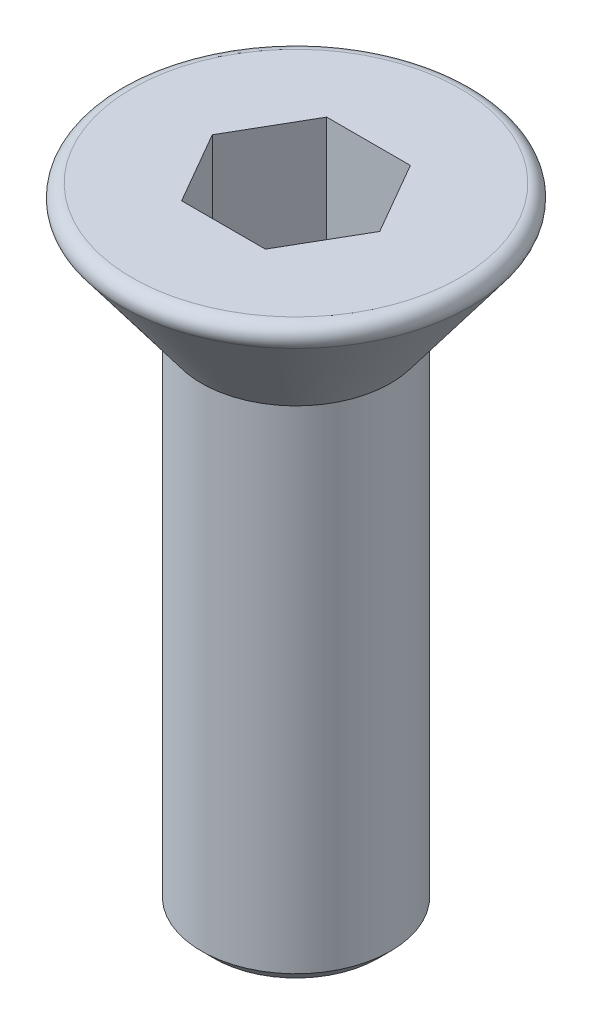
from build123d import *

# Parameters (mm, degrees)
SKETCH_2_R          = 1.5
EXTRUDE_1_DEPTH     = 8
CUT_EXTRUDE_1_DEPTH = 2
CHAMFER_1_SIZE      = 0.2
FILLET_1_R          = 0.2


with BuildPart() as part:
    # 草图1 → 旋转1 (revolve)
    with BuildSketch(Plane.XY):
        Polygon((0, 0), (0, -2), (1.5, -2), (3, 0), align=None)
    revolve(axis=Axis((0, 0, 0), (0, -1, 0)))

    # 草图2 → 凸台-拉伸1 (add)
    with BuildSketch(Plane.XZ.offset(2)):
        Circle(SKETCH_2_R)
    extrude(amount=EXTRUDE_1_DEPTH)

    # 草图3 → 切除-拉伸1 (cut)
    with BuildSketch(Plane(origin=(0, 0, 0), x_dir=(1, 0, 0), z_dir=(0, 1, 0))):
        Polygon((-1.327905619, 0), (-0.66395281, -1.15), (0.66395281, -1.15), (1.327905619, 0), (0.66395281, 1.15), (-0.66395281, 1.15), align=None)
    extrude(amount=-CUT_EXTRUDE_1_DEPTH, mode=Mode.SUBTRACT)

    # 倒角1
    chamfer_1_edges = [part.edges().sort_by_distance(p)[0] for p in [
        (-1.5, -10, 0),
    ]]
    chamfer(chamfer_1_edges, length=CHAMFER_1_SIZE)

    # 圆角1
    fillet_1_edges = [part.edges().sort_by_distance(p)[0] for p in [
        (-3, 0, 0),
    ]]
    fillet(fillet_1_edges, radius=FILLET_1_R)


solid = part.part
